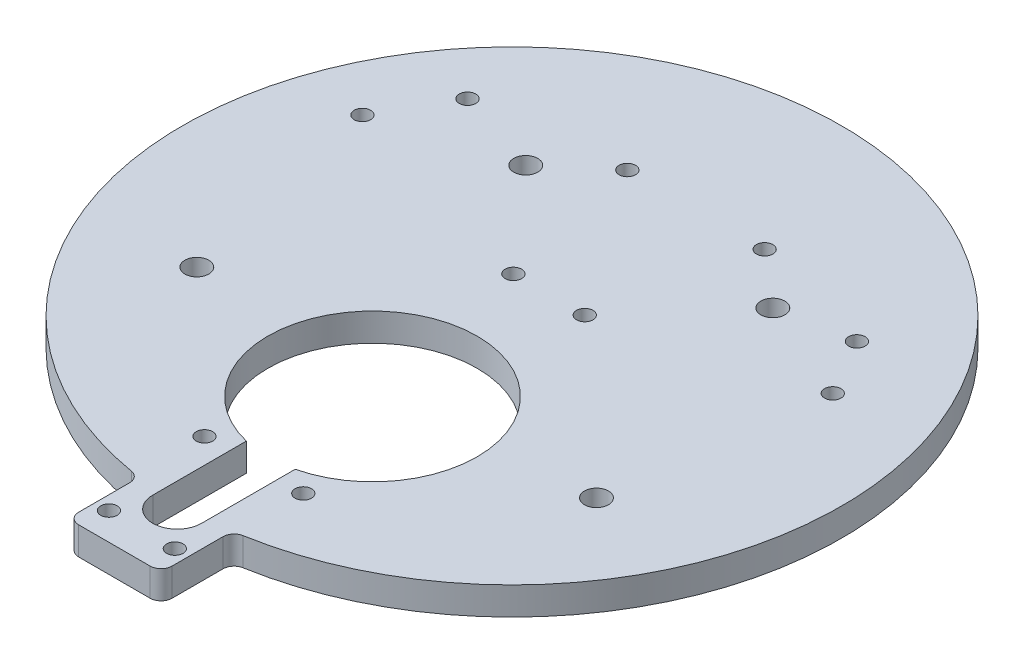
from build123d import *

# Parameters (mm, degrees)
SKETCH1_R           = 60
BOSS_EXTRUDE1_DEPTH = 5.08
SKETCH2_R           = 2.1828125
CUT_EXTRUDE1_DEPTH  = 6.08
CIRPATTERN1_COUNT   = 2
CIRPATTERN1_ANGLE   = 120
SKETCH3_R           = 1.5
CUT_EXTRUDE2_DEPTH  = 6.08
SKETCH5_R           = 2.1828125
CUT_EXTRUDE4_DEPTH  = 6.08
SKETCH6_R           = 19.05
CUT_EXTRUDE5_DEPTH  = 6.08
SKETCH9_W           = 17
SKETCH9_H           = 13
BOSS_EXTRUDE2_DEPTH = 5.08
SKETCH7_R           = 1.5
CUT_EXTRUDE6_DEPTH  = 6.08
FILLET1_R           = 2
FILLET2_R           = 2


with BuildPart() as part:
    # Sketch1 → Boss-Extrude1 (new body)
    with BuildSketch(Plane(origin=(0, 0, 0), x_dir=(1, 0, 0), z_dir=(0, 1, 0))):
        Circle(SKETCH1_R)
    extrude(amount=BOSS_EXTRUDE1_DEPTH)

    # Sketch2 → Cut-Extrude1 (cut, through all)
    with BuildSketch(Plane(origin=(0, 5.08, 0), x_dir=(1, 0, 0), z_dir=(0, 1, 0))):
        with Locations((-36.386057378, -21.007500022)):
            Circle(SKETCH2_R)
    cut_extrude1 = extrude(amount=-CUT_EXTRUDE1_DEPTH, mode=Mode.SUBTRACT)

    # CirPattern1: Cut-Extrude1 ×2 about axis
    cirpattern1_axis = Axis((0, 5.08, 0), (0, 1, 0))
    for i in range(1, CIRPATTERN1_COUNT):
        add(cut_extrude1.rotate(cirpattern1_axis, i * CIRPATTERN1_ANGLE / (CIRPATTERN1_COUNT - 1)), mode=Mode.SUBTRACT)

    # Sketch3 → Cut-Extrude2 (cut, through all)
    with BuildSketch(Plane(origin=(0, 5.08, 0), x_dir=(1, 0, 0), z_dir=(0, 1, 0))):
        with Locations((-6.5, 6.749999962)):
            Circle(SKETCH3_R)
        with Locations((6.5, 6.749999962)):
            Circle(SKETCH3_R)
        with Locations((-12.5, 33.500000056)):
            Circle(SKETCH3_R)
        with Locations((12.5, 33.500000056)):
            Circle(SKETCH3_R)
        with Locations((35.421216966, 27.378652381)):
            Circle(SKETCH3_R)
        with Locations((41.421216966, 16.986347535)):
            Circle(SKETCH3_R)
        with Locations((-45.294385987, 18.067822174)):
            Circle(SKETCH3_R)
        with Locations((-38.294385987, 30.192177826)):
            Circle(SKETCH3_R)
    extrude(amount=-CUT_EXTRUDE2_DEPTH, mode=Mode.SUBTRACT)

    # Sketch5 → Cut-Extrude4 (cut, through all)
    with BuildSketch(Plane(origin=(0, 5.08, 0), x_dir=(1, 0, 0), z_dir=(0, 1, 0))):
        with Locations((-22.5, 25)):
            Circle(SKETCH5_R)
        with Locations((22.5, 25)):
            Circle(SKETCH5_R)
    extrude(amount=-CUT_EXTRUDE4_DEPTH, mode=Mode.SUBTRACT)

    # Sketch6 → Cut-Extrude5 (cut, through all)
    with BuildSketch(Plane(origin=(0, 5.08, 0), x_dir=(1, 0, 0), z_dir=(0, 1, 0))):
        with Locations((0, -25.4)):
            Circle(SKETCH6_R)
    extrude(amount=-CUT_EXTRUDE5_DEPTH, mode=Mode.SUBTRACT)

    # Sketch9 → Boss-Extrude2 (add)
    with BuildSketch(Plane(origin=(0, 5.08, 0), x_dir=(1, 0, 0), z_dir=(0, 1, 0))):
        with Locations((0, -65.894865098)):
            Rectangle(SKETCH9_W, SKETCH9_H)
    extrude(amount=-BOSS_EXTRUDE2_DEPTH)

    # Sketch7 → Cut-Extrude6 (cut, through all)
    with BuildSketch(Plane(origin=(0, 5.08, 0), x_dir=(1, 0, 0), z_dir=(0, 1, 0))):
        with Locations((-9, -47)):
            Circle(SKETCH7_R)
        with Locations((-6, -67.394865098)):
            Circle(SKETCH7_R)
        with Locations((6, -67.394865098)):
            Circle(SKETCH7_R)
        with Locations((9, -47)):
            Circle(SKETCH7_R)
        with BuildLine():
            Line((-4.445, -60.964865098), (-4.445, -43.924159225))
            Line((-4.445, -43.924159225), (4.445, -43.924159225))
            Line((4.445, -43.924159225), (4.445, -60.964865098))
            ThreePointArc((4.445, -60.964865098), (0, -65.409865098), (-4.445, -60.964865098))
        make_face()
    extrude(amount=-CUT_EXTRUDE6_DEPTH, mode=Mode.SUBTRACT)

    # Fillet1
    fillet1_edges = [part.edges().sort_by_distance(p)[0] for p in [
        (8.5, 2.54, 72.394865098),
        (-8.5, 2.54, 72.394865098),
    ]]
    fillet(fillet1_edges, radius=FILLET1_R)

    # Fillet2
    fillet2_edges = [part.edges().sort_by_distance(p)[0] for p in [
        (8.5, 2.54, 59.394865098),
        (-8.5, 2.54, 59.394865098),
    ]]
    fillet(fillet2_edges, radius=FILLET2_R)


solid = part.part
